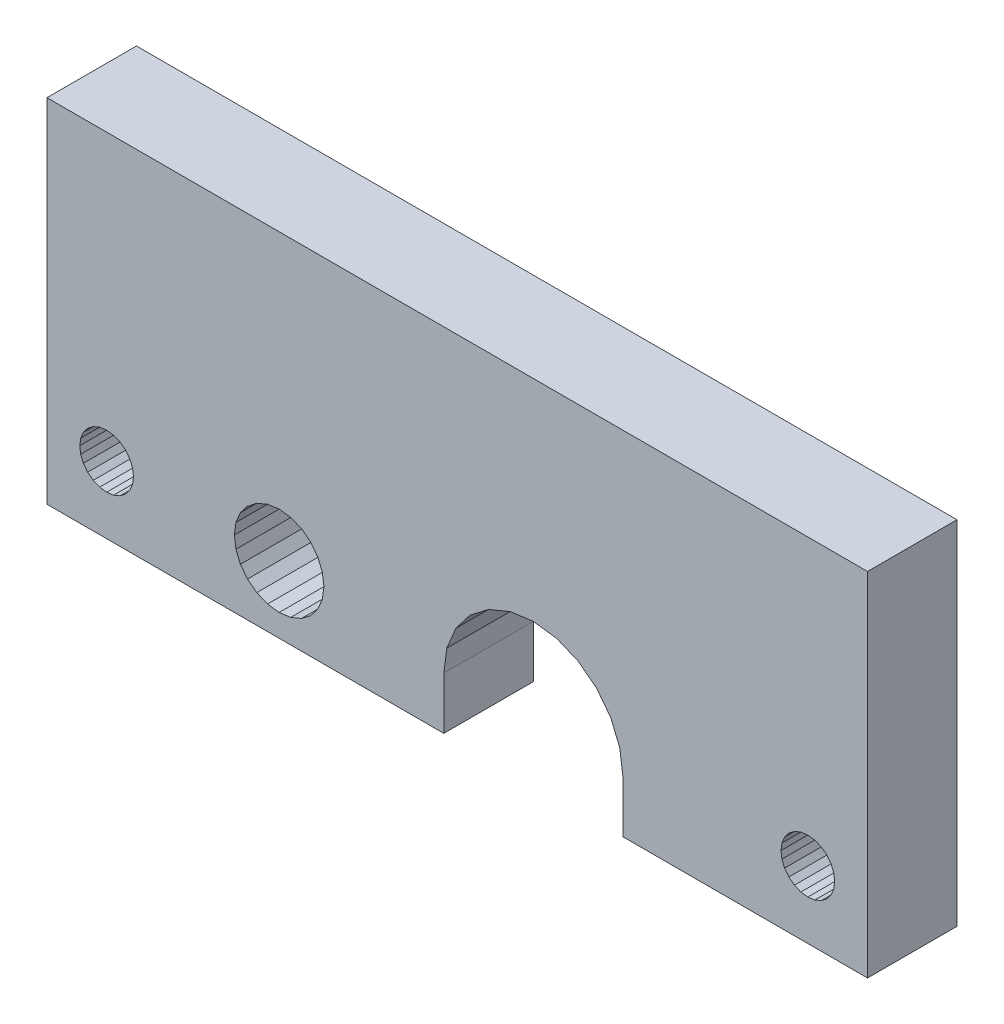
from build123d import *

# Parameters (mm, degrees)
BOSS_EXTRUDE1_DEPTH = 6


with BuildPart() as part:
    # Sketch1 → Boss-Extrude1 (new body)
    with BuildSketch(Plane.XY):
        Polygon((-506.545769475, -193.251863484), (-506.545769475, -169.651863484), (-451.545769475, -169.651863484), (-451.545769475, -193.251863484), (-467.945769475, -193.251863484), (-467.945769475, -189.751863484), (-468.150214517, -188.198949213), (-468.749617052, -186.751863484), (-469.703128788, -185.509222797), (-470.945769475, -184.555711061), (-472.392855205, -183.956308526), (-473.945769475, -183.751863484), (-475.498683746, -183.956308526), (-476.945769475, -184.555711061), (-478.188410162, -185.509222797), (-479.141921898, -186.751863484), (-479.741324433, -188.198949213), (-479.945769475, -189.751863484), (-479.945769475, -193.251863484), align=None)
        Polygon((-455.545769475, -190.551863484), (-455.079895194, -190.490529971), (-454.645769475, -190.310709211), (-454.272977269, -190.02465569), (-453.986923748, -189.651863484), (-453.807102988, -189.217737765), (-453.745769475, -188.751863484), (-453.807102988, -188.285989203), (-453.986923748, -187.851863484), (-454.272977269, -187.479071278), (-454.645769475, -187.193017757), (-455.079895194, -187.013196996), (-455.545769475, -186.951863484), (-456.011643756, -187.013196996), (-456.445769475, -187.193017757), (-456.818561681, -187.479071278), (-457.104615202, -187.851863484), (-457.284435962, -188.285989203), (-457.345769475, -188.751863484), (-457.284435962, -189.217737765), (-457.104615202, -189.651863484), (-456.818561681, -190.02465569), (-456.445769475, -190.310709211), (-456.011643756, -190.490529971), align=None, mode=Mode.SUBTRACT)
        Polygon((-502.079895194, -190.490529971), (-501.645769475, -190.310709211), (-501.272977269, -190.02465569), (-500.986923748, -189.651863484), (-500.807102988, -189.217737765), (-500.745769475, -188.751863484), (-500.807102988, -188.285989203), (-500.986923748, -187.851863484), (-501.272977269, -187.479071278), (-501.645769475, -187.193017757), (-502.079895194, -187.013196996), (-502.545769475, -186.951863484), (-503.011643756, -187.013196996), (-503.445769475, -187.193017757), (-503.818561681, -187.479071278), (-504.104615202, -187.851863484), (-504.284435962, -188.285989203), (-504.345769475, -188.751863484), (-504.284435962, -189.217737765), (-504.104615202, -189.651863484), (-503.818561681, -190.02465569), (-503.445769475, -190.310709211), (-503.011643756, -190.490529971), (-502.545769475, -190.551863484), align=None, mode=Mode.SUBTRACT)
        Polygon((-492.445769475, -186.153787272), (-492.482936855, -186.153787272), (-493.067089819, -186.63054314), (-493.104257199, -186.63054314), (-493.581013066, -187.251863484), (-493.880714334, -187.975406348), (-493.982936855, -188.751863484), (-493.880714334, -189.528320619), (-493.581013066, -190.251863484), (-493.104257199, -190.873183827), (-492.482936855, -191.349939695), (-491.75939399, -191.649640963), (-490.982936855, -191.751863484), (-490.20647972, -191.649640963), (-489.482936855, -191.349939695), (-488.861616511, -190.873183827), (-488.384860644, -190.251863484), (-488.085159376, -189.528320619), (-487.982936855, -188.751863484), (-488.085159376, -187.975406348), (-488.384860644, -187.251863484), (-488.861616511, -186.63054314), (-489.445769475, -186.153787272), (-489.482936855, -186.153787272), (-490.16931234, -185.854086005), (-490.20647972, -185.854086005), (-490.945769475, -185.751863484), (-490.982936855, -185.751863484), (-491.72222661, -185.854086005), (-491.75939399, -185.854086005), align=None, mode=Mode.SUBTRACT)
    extrude(amount=BOSS_EXTRUDE1_DEPTH)


solid = part.part
